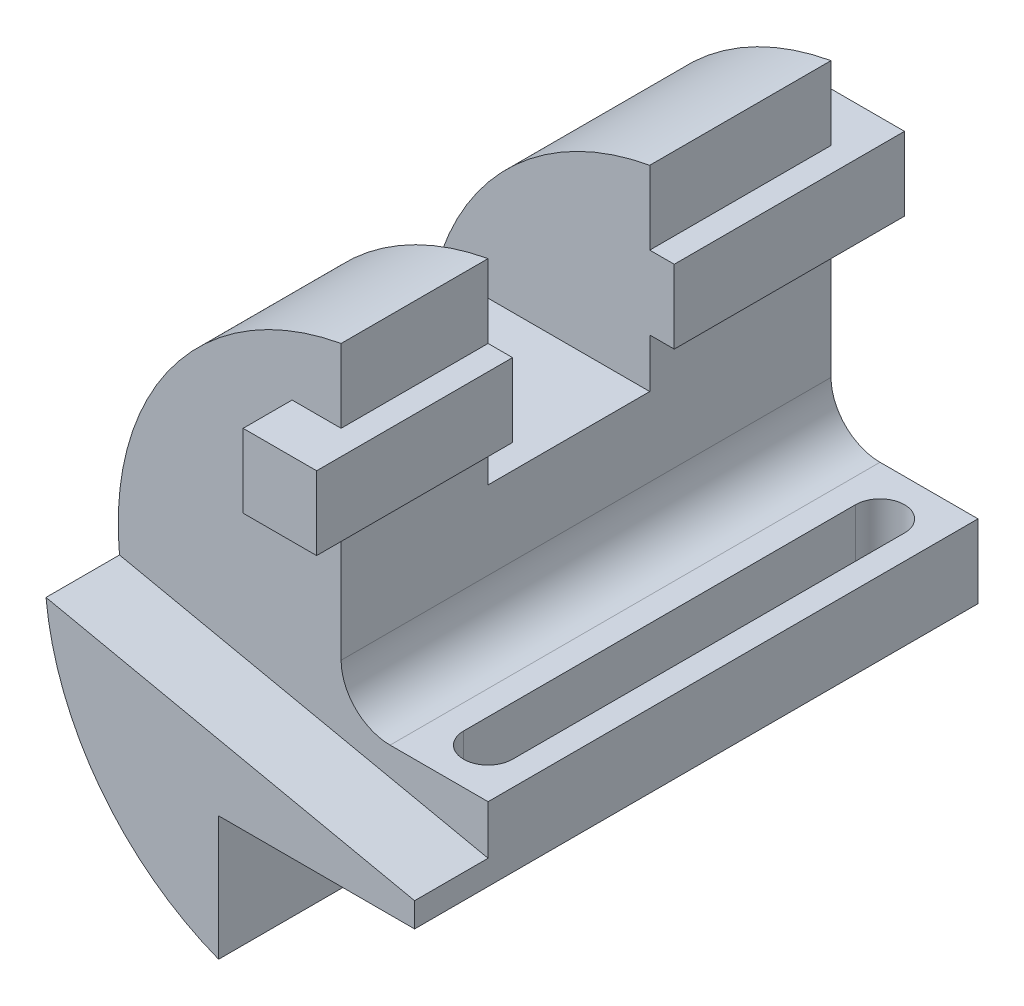
from build123d import *

# Parameters (mm, degrees)
SKETCH1_W                = 10
SKETCH1_H                = 15
BOSS_EXTRUDE1_DEPTH      = 115
SKETCH1_5_W              = 10
SKETCH1_5_H              = 15
CUT_EXTRUDE1_DEPTH       = 15
SKETCH6_W                = 15
SKETCH6_H                = 15
BOSS_EXTRUDE3_DEPTH      = 52.5
BOSS_EXTRUDE3_DEPTH_BACK = 67.5
CUT_EXTRUDE2_REACH       = 52.5
SKETCH7_W                = 33
SKETCH7_H                = 40
CUT_EXTRUDE3_DEPTH       = 15


with BuildPart() as part:
    # Sketch1 → Boss-Extrude1 (new body)
    with BuildSketch(Plane.XY):
        with BuildLine():
            Line((-10, 91.362796982), (-10, 106.362796982))
            ThreePointArc((-10, 106.362796982), (-44.318751046, 85.179188449), (-55.235044142, 46.354499282))
            Line((-55.235044142, 46.354499282), (20, 30.362796982))
            Line((20, 30.362796982), (20, 40.362796982))
            Line((20, 40.362796982), (0, 40.362796982))
            ThreePointArc((0, 40.362796982), (-7.071067812, 43.29172917), (-10, 50.362796982))
            Line((-10, 50.362796982), (-10, 76.362796982))
            Line((-10, 76.362796982), (-20, 76.362796982))
            Line((-20, 76.362796982), (-20, 91.362796982))
            Line((-20, 91.362796982), (-10, 91.362796982))
        make_face()
        with BuildLine():
            Line((20, 30.362796982), (-55.235044142, 46.354499282))
            ThreePointArc((-55.235044142, 46.354499282), (-44.184418834, 18.185611269), (-20, 0))
            Line((-20, 0), (-20, 25.362796982))
            Line((-20, 25.362796982), (20, 25.362796982))
            Line((20, 25.362796982), (20, 30.362796982))
        make_face()
        with Locations((-15, 83.862796982)):
            Rectangle(SKETCH1_W, SKETCH1_H)
    extrude(amount=-BOSS_EXTRUDE1_DEPTH)

    # Sketch1_5 → Cut-Extrude1 (cut)
    with BuildSketch(Plane.XY):
        with BuildLine():
            Line((-10, 91.362796982), (-10, 106.362796982))
            ThreePointArc((-10, 106.362796982), (-44.318751046, 85.179188449), (-55.235044142, 46.354499282))
            Line((-55.235044142, 46.354499282), (20, 30.362796982))
            Line((20, 30.362796982), (20, 40.362796982))
            Line((20, 40.362796982), (0, 40.362796982))
            ThreePointArc((0, 40.362796982), (-7.071067812, 43.29172917), (-10, 50.362796982))
            Line((-10, 50.362796982), (-10, 76.362796982))
            Line((-10, 76.362796982), (-20, 76.362796982))
            Line((-20, 76.362796982), (-20, 91.362796982))
            Line((-20, 91.362796982), (-10, 91.362796982))
        make_face()
        with Locations((-15, 83.862796982)):
            Rectangle(SKETCH1_5_W, SKETCH1_5_H)
    extrude(amount=-CUT_EXTRUDE1_DEPTH, mode=Mode.SUBTRACT)

    # Sketch6 → Boss-Extrude3 (add, two sides)
    with BuildSketch(Plane.XY.offset(-57.5)) as boss_extrude3_sk:
        with Locations((-12.5, 83.862796982)):
            Rectangle(SKETCH6_W, SKETCH6_H)
    extrude(amount=BOSS_EXTRUDE3_DEPTH)
    extrude(boss_extrude3_sk.sketch, amount=-BOSS_EXTRUDE3_DEPTH_BACK)

    # Sketch7 → Cut-Extrude2 (cut, up to next)
    with BuildSketch(Plane(origin=(-5, 0, 0), x_dir=(0, 0, -1), z_dir=(1, 0, 0)), mode=Mode.PRIVATE) as cut_extrude2_sk1:
        with Locations((61.5, 86.362796982)):
            Rectangle(SKETCH7_W, SKETCH7_H)
    cut_extrude2_tool1 = extrude(cut_extrude2_sk1.sketch, amount=-CUT_EXTRUDE2_REACH, mode=Mode.PRIVATE) & part.part
    add(cut_extrude2_tool1.solids().sort_by_distance((-5, 86.362797, -61.5))[0], mode=Mode.SUBTRACT)

    # Sketch8 → Cut-Extrude3 (cut)
    with BuildSketch(Plane(origin=(0, 40.362796982, 0), x_dir=(1, 0, 0), z_dir=(0, 1, 0))):
        with BuildLine():
            Line((5, 25), (5, 105))
            ThreePointArc((5, 105), (10, 110), (15, 105))
            Line((15, 105), (15, 25))
            ThreePointArc((15, 25), (10, 20), (5, 25))
        make_face()
    extrude(amount=-CUT_EXTRUDE3_DEPTH, mode=Mode.SUBTRACT)


solid = part.part
